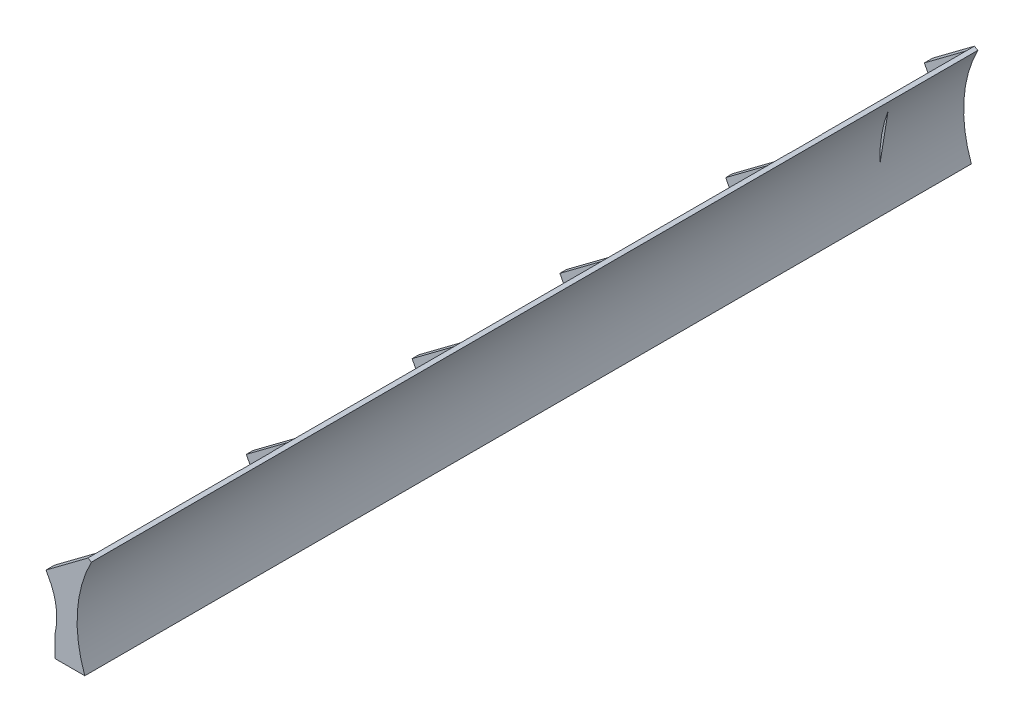
from build123d import *

# Parameters (mm, degrees)
BOSS_EXTRU_1_DEPTH       = 270
ENL_V_MAT_EXTRU_4_DEPTH  = 26
ENL_V_MAT_EXTRU_5_DEPTH  = 20
ENL_V_MAT_EXTRU_6_DEPTH  = 42
ENL_V_MAT_EXTRU_7_DEPTH  = 19
ENL_V_MAT_EXTRU_8_DEPTH  = 10
ENL_V_MAT_EXTRU_9_DEPTH  = 10
ENL_V_MAT_EXTRU_10_DEPTH = 77
ENL_V_MAT_EXTRU_11_DEPTH = 10
ENL_V_MAT_EXTRU_12_DEPTH = 10
ENL_V_MAT_EXTRU_13_DEPTH = 37


with BuildPart() as part:
    # Esquisse1 → Boss.-Extru.1 (new body)
    with BuildSketch(Plane.XY):
        with BuildLine():
            Line((16.063962193, 30.398965806), (13.815004567, 31.398965806))
            Line((13.815004567, 31.398965806), (-11.613167833, 12.388079656))
            Line((-11.613167833, 12.388079656), (-8.463957616, 6.398855993))
            ThreePointArc((-8.463957616, 6.398855993), (-5.270411832, -5.520215773), (-5.985086805, -17.838991935))
            Line((-5.985086805, -17.838991935), (-5.985086805, -31.601034194))
            Line((-5.985086805, -31.601034194), (12.014913195, -31.601034194))
            ThreePointArc((12.014913195, -31.601034194), (7.480174869, -0.17266683), (16.063962193, 30.398965806))
        make_face()
    boss_extru_1 = extrude(amount=BOSS_EXTRU_1_DEPTH)

    # Esquisse3 → Enlèv. mat.-Extru.4 (cut)
    with BuildSketch(Plane.XY.offset(265)):
        with BuildLine():
            Line((-8.463957616, 6.398855993), (-11.613167833, 12.388079656))
            Line((-11.613167833, 12.388079656), (13.815004567, 31.398965806))
            ThreePointArc((13.815004567, 31.398965806), (4.532085849, 7.647429334), (3.665832045, -17.838991935))
            Line((3.665832045, -17.838991935), (-5.985086805, -17.838991935))
            ThreePointArc((-5.985086805, -17.838991935), (-5.270411832, -5.520215773), (-8.463957616, 6.398855993))
        make_face()
    enl_v_mat_extru_4 = extrude(amount=-ENL_V_MAT_EXTRU_4_DEPTH, mode=Mode.SUBTRACT)

    # Esquisse5 → Enlèv. mat.-Extru.5 (cut)
    with BuildSketch(Plane.XY.offset(239)):
        with BuildLine():
            Line((-8.463959076, 6.398857946), (-11.613169295, 12.388081611))
            Line((-11.613169295, 12.388081611), (13.815004567, 31.398965806))
            ThreePointArc((13.815004567, 31.398965806), (4.067679065, 5.247942268), (4.28050542, -22.659782317))
            Line((4.28050542, -22.659782317), (4.28050542, -27.25252086))
            Line((4.28050542, -27.25252086), (-5.985086805, -27.25252086))
            Line((-5.985086805, -27.25252086), (-5.985086805, -17.838991935))
            ThreePointArc((-5.985086805, -17.838991935), (-5.270412229, -5.520214661), (-8.463959076, 6.398857946))
        make_face()
    enl_v_mat_extru_5 = extrude(amount=-ENL_V_MAT_EXTRU_5_DEPTH, mode=Mode.SUBTRACT)

    # Esquisse6 → Enlèv. mat.-Extru.6 (cut)
    with BuildSketch(Plane.XY.offset(219)):
        with BuildLine():
            Line((-8.463957616, 6.398855993), (-11.613167833, 12.388079656))
            Line((-11.613167833, 12.388079656), (13.815004567, 31.398965806))
            ThreePointArc((13.815004567, 31.398965806), (10.20595229, 24.654084621), (7.296301708, 17.579297414))
            Line((7.296301708, 17.579297414), (-8.463957616, 6.398855993))
        make_face()
    enl_v_mat_extru_6 = extrude(amount=-ENL_V_MAT_EXTRU_6_DEPTH, mode=Mode.SUBTRACT)

    # Esquisse9 → Enlèv. mat.-Extru.7 (cut)
    with BuildSketch(Plane.XY.offset(177)):
        with BuildLine():
            Line((-8.521548111, 6.142905843), (-11.984807414, 12.729393608))
            Line((-11.984807414, 12.729393608), (14.702039036, 32.681300109))
            ThreePointArc((14.702039036, 32.681300109), (4.172070852, 5.87993715), (4.222916385, -22.91573442))
            Line((4.222916385, -22.91573442), (4.222916385, -27.508472963))
            Line((4.222916385, -27.508472963), (-6.04267584, -27.508472963))
            Line((-6.04267584, -27.508472963), (-6.04267584, -18.094944039))
            ThreePointArc((-6.04267584, -18.094944039), (-5.328001264, -5.776166764), (-8.521548111, 6.142905843))
        make_face()
    enl_v_mat_extru_7 = extrude(amount=-ENL_V_MAT_EXTRU_7_DEPTH, mode=Mode.SUBTRACT)

    # Esquisse10 → Enlèv. mat.-Extru.8 (cut)
    with BuildSketch(Plane.XY.offset(158)):
        with BuildLine():
            Line((-8.463957616, 6.398855993), (-11.613167833, 12.388079656))
            Line((-11.613167833, 12.388079656), (13.815004567, 31.398965806))
            ThreePointArc((13.815004567, 31.398965806), (4.532085849, 7.647429334), (3.665832045, -17.838991935))
            Line((3.665832045, -17.838991935), (-5.985086805, -17.838991935))
            ThreePointArc((-5.985086805, -17.838991935), (-5.270411832, -5.520215773), (-8.463957616, 6.398855993))
        make_face()
    enl_v_mat_extru_8 = extrude(amount=-ENL_V_MAT_EXTRU_8_DEPTH, mode=Mode.SUBTRACT)

    # Esquisse11 → Enlèv. mat.-Extru.9 (cut)
    with BuildSketch(Plane.XY.offset(144)):
        with BuildLine():
            Line((-8.463957616, 6.398855993), (-11.613167833, 12.388079656))
            Line((-11.613167833, 12.388079656), (13.815004567, 31.398965806))
            ThreePointArc((13.815004567, 31.398965806), (4.532085849, 7.647429334), (3.665832045, -17.838991935))
            Line((3.665832045, -17.838991935), (-5.985086805, -17.838991935))
            ThreePointArc((-5.985086805, -17.838991935), (-5.270411832, -5.520215773), (-8.463957616, 6.398855993))
        make_face()
    enl_v_mat_extru_9 = extrude(amount=-ENL_V_MAT_EXTRU_9_DEPTH, mode=Mode.SUBTRACT)

    # Esquisse12 → Enlèv. mat.-Extru.10 (cut)
    with BuildSketch(Plane.XY.offset(134)):
        with BuildLine():
            Line((-8.463959076, 6.398857946), (-11.613169295, 12.388081611))
            Line((-11.613169295, 12.388081611), (13.815004567, 31.398965806))
            ThreePointArc((13.815004567, 31.398965806), (4.067679065, 5.247942268), (4.28050542, -22.659782317))
            Line((4.28050542, -22.659782317), (4.28050542, -27.25252086))
            Line((4.28050542, -27.25252086), (-5.985086805, -27.25252086))
            Line((-5.985086805, -27.25252086), (-5.985086805, -17.838991935))
            ThreePointArc((-5.985086805, -17.838991935), (-5.270412229, -5.520214661), (-8.463959076, 6.398857946))
        make_face()
    enl_v_mat_extru_10 = extrude(amount=-ENL_V_MAT_EXTRU_10_DEPTH, mode=Mode.SUBTRACT)

    # Esquisse13 → Enlèv. mat.-Extru.11 (cut)
    with BuildSketch(Plane.XY.offset(57)):
        with BuildLine():
            Line((-8.463957616, 6.398855993), (-11.613167833, 12.388079656))
            Line((-11.613167833, 12.388079656), (13.815004567, 31.398965806))
            ThreePointArc((13.815004567, 31.398965806), (4.532085849, 7.647429334), (3.665832045, -17.838991935))
            Line((3.665832045, -17.838991935), (-5.985086805, -17.838991935))
            ThreePointArc((-5.985086805, -17.838991935), (-5.270411832, -5.520215773), (-8.463957616, 6.398855993))
        make_face()
    enl_v_mat_extru_11 = extrude(amount=-ENL_V_MAT_EXTRU_11_DEPTH, mode=Mode.SUBTRACT)

    # Esquisse14 → Enlèv. mat.-Extru.12 (cut)
    with BuildSketch(Plane.XY.offset(43)):
        with BuildLine():
            Line((-8.463957616, 6.398855993), (-11.613167833, 12.388079656))
            Line((-11.613167833, 12.388079656), (13.815004567, 31.398965806))
            ThreePointArc((13.815004567, 31.398965806), (4.532085849, 7.647429334), (3.665832045, -17.838991935))
            Line((3.665832045, -17.838991935), (-5.985086805, -17.838991935))
            ThreePointArc((-5.985086805, -17.838991935), (-5.270411832, -5.520215773), (-8.463957616, 6.398855993))
        make_face()
    enl_v_mat_extru_12 = extrude(amount=-ENL_V_MAT_EXTRU_12_DEPTH, mode=Mode.SUBTRACT)

    # Esquisse15 → Enlèv. mat.-Extru.13 (cut)
    with BuildSketch(Plane.XY.offset(33)):
        with BuildLine():
            Line((-8.463959076, 6.398857946), (-11.613169295, 12.388081611))
            Line((-11.613169295, 12.388081611), (13.815004567, 31.398965806))
            ThreePointArc((13.815004567, 31.398965806), (4.067679065, 5.247942268), (4.28050542, -22.659782317))
            Line((4.28050542, -22.659782317), (4.28050542, -27.25252086))
            Line((4.28050542, -27.25252086), (-5.985086805, -27.25252086))
            Line((-5.985086805, -27.25252086), (-5.985086805, -17.838991935))
            ThreePointArc((-5.985086805, -17.838991935), (-5.270412229, -5.520214661), (-8.463959076, 6.398857946))
        make_face()
    enl_v_mat_extru_13 = extrude(amount=-ENL_V_MAT_EXTRU_13_DEPTH, mode=Mode.SUBTRACT)

    # Symétrie1: Boss.-Extru.1, Enlèv. mat.-Extru.4, Enlèv. mat.-Extru.5, Enlèv. mat.-Extru.6, Enlèv. mat.-Extru.7, Enlèv. mat.-Extru.8, Enlèv. mat.-Extru.9, Enlèv. mat.-Extru.10, Enlèv. mat.-Extru.11, Enlèv. mat.-Extru.12, Enlèv. mat.-Extru.13 across plane
    add(boss_extru_1.mirror(Plane(origin=(0, 0, 0), x_dir=(1, 0, 0), z_dir=(0, 0, -1))))
    add(enl_v_mat_extru_4.mirror(Plane(origin=(0, 0, 0), x_dir=(1, 0, 0), z_dir=(0, 0, -1))), mode=Mode.SUBTRACT)
    add(enl_v_mat_extru_5.mirror(Plane(origin=(0, 0, 0), x_dir=(1, 0, 0), z_dir=(0, 0, -1))), mode=Mode.SUBTRACT)
    add(enl_v_mat_extru_6.mirror(Plane(origin=(0, 0, 0), x_dir=(1, 0, 0), z_dir=(0, 0, -1))), mode=Mode.SUBTRACT)
    add(enl_v_mat_extru_7.mirror(Plane(origin=(0, 0, 0), x_dir=(1, 0, 0), z_dir=(0, 0, -1))), mode=Mode.SUBTRACT)
    add(enl_v_mat_extru_8.mirror(Plane(origin=(0, 0, 0), x_dir=(1, 0, 0), z_dir=(0, 0, -1))), mode=Mode.SUBTRACT)
    add(enl_v_mat_extru_9.mirror(Plane(origin=(0, 0, 0), x_dir=(1, 0, 0), z_dir=(0, 0, -1))), mode=Mode.SUBTRACT)
    add(enl_v_mat_extru_10.mirror(Plane(origin=(0, 0, 0), x_dir=(1, 0, 0), z_dir=(0, 0, -1))), mode=Mode.SUBTRACT)
    add(enl_v_mat_extru_11.mirror(Plane(origin=(0, 0, 0), x_dir=(1, 0, 0), z_dir=(0, 0, -1))), mode=Mode.SUBTRACT)
    add(enl_v_mat_extru_12.mirror(Plane(origin=(0, 0, 0), x_dir=(1, 0, 0), z_dir=(0, 0, -1))), mode=Mode.SUBTRACT)
    add(enl_v_mat_extru_13.mirror(Plane(origin=(0, 0, 0), x_dir=(1, 0, 0), z_dir=(0, 0, -1))), mode=Mode.SUBTRACT)

    # Esquisse27 → Trou taraudé G1/162 (revolve, cut)
    with BuildSketch(Plane(origin=(3.014913195, -31.601034194, 247), x_dir=(0, 0, -1), z_dir=(1, 0, 0))):
        Polygon((0, 0), (0, 12), (3.3, 10.017159957), (3.3, 0), align=None)
    trou_taraud_g1_162 = revolve(axis=Axis((3.014913195, -37.951034194, 247), (0, 1, 0)), mode=Mode.SUBTRACT)

    # Esquisse28 → Trou taraudé G1/163 (revolve, cut)
    with BuildSketch(Plane(origin=(2.950249404, -31.601034194, 146), x_dir=(0, 0, -1), z_dir=(1, 0, 0))):
        Polygon((0, 0), (0, 12), (3.3, 10.017159957), (3.3, 0), align=None)
    trou_taraud_g1_163 = revolve(axis=Axis((2.950249404, -37.951034194, 146), (0, 1, 0)), mode=Mode.SUBTRACT)

    # Esquisse29 → Trou taraudé G1/164 (revolve, cut)
    with BuildSketch(Plane(origin=(3.014913195, -31.601034194, 45), x_dir=(0, 0, -1), z_dir=(1, 0, 0))):
        Polygon((0, 0), (0, 12), (3.3, 10.017159957), (3.3, 0), align=None)
    trou_taraud_g1_164 = revolve(axis=Axis((3.014913195, -37.951034194, 45), (0, 1, 0)), mode=Mode.SUBTRACT)

    # Symétrie2: Trou taraudé G1/162, Trou taraudé G1/163, Trou taraudé G1/164 across plane
    add(trou_taraud_g1_162.mirror(Plane(origin=(0, 0, 0), x_dir=(1, 0, 0), z_dir=(0, 0, -1))), mode=Mode.SUBTRACT)
    add(trou_taraud_g1_163.mirror(Plane(origin=(0, 0, 0), x_dir=(1, 0, 0), z_dir=(0, 0, -1))), mode=Mode.SUBTRACT)
    add(trou_taraud_g1_164.mirror(Plane(origin=(0, 0, 0), x_dir=(1, 0, 0), z_dir=(0, 0, -1))), mode=Mode.SUBTRACT)


solid = part.part
